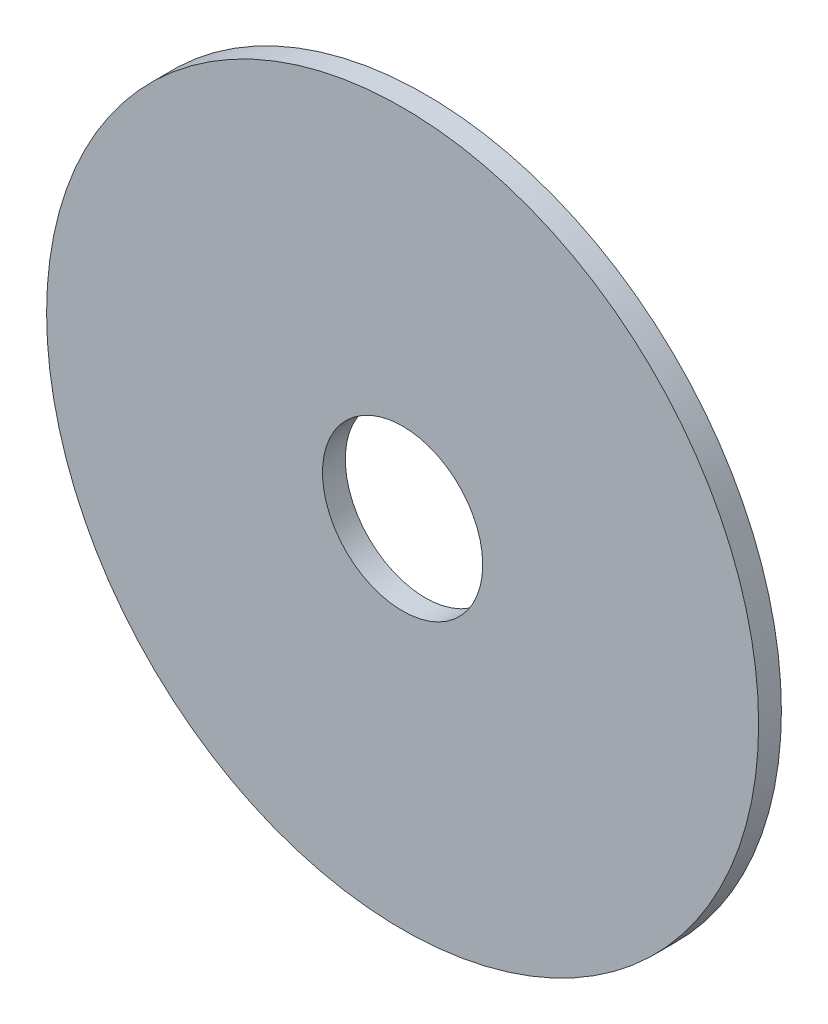
from build123d import *

# Parameters (mm, degrees)
SKETCH1_R      = 15.875
SKETCH1_R_2    = 3.571875
EXTRUDE1_DEPTH = 1.016


with BuildPart() as part:
    # Sketch1 → Extrude1 (new body)
    with BuildSketch(Plane.XY):
        Circle(SKETCH1_R)
        Circle(SKETCH1_R_2, mode=Mode.SUBTRACT)
    extrude(amount=-EXTRUDE1_DEPTH)


solid = part.part
